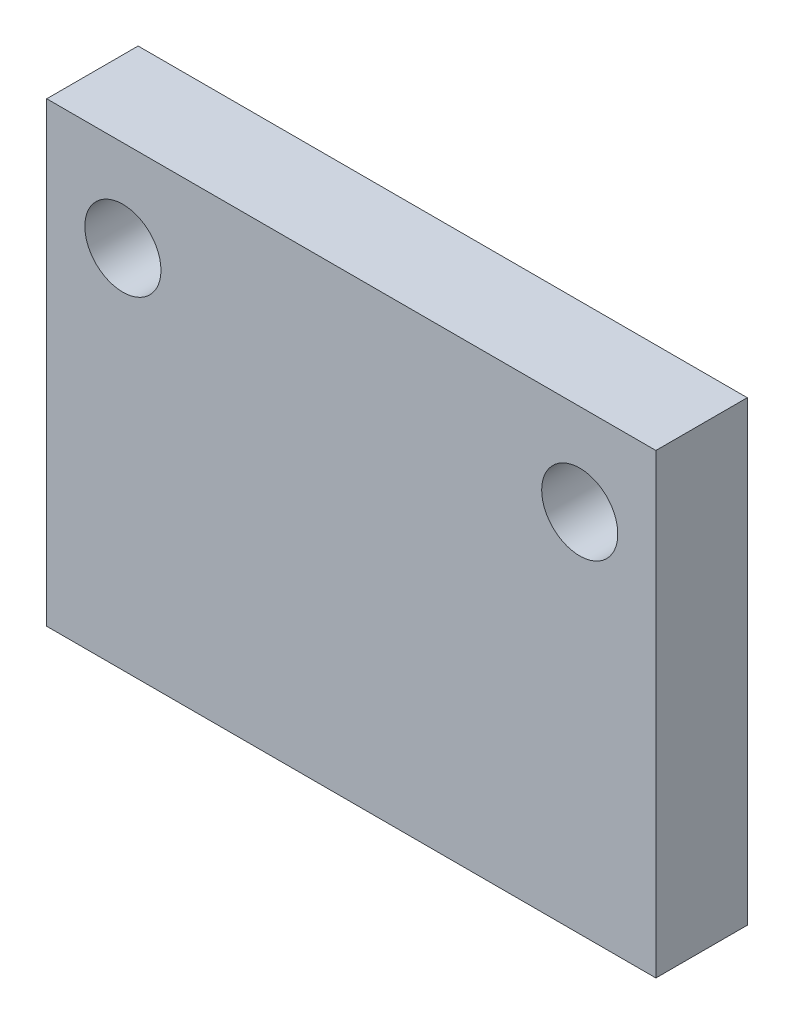
from build123d import *

# Parameters (mm, degrees)
SKETCH_1_W      = 20
SKETCH_1_H      = 15
SKETCH_1_R      = 1.25
EXTRUDE_1_DEPTH = 3


with BuildPart() as part:
    # 草图1 → 凸台-拉伸1 (new body)
    with BuildSketch(Plane.XY):
        Rectangle(SKETCH_1_W, SKETCH_1_H)
        with Locations((-7.5, 4.5)):
            Circle(SKETCH_1_R, mode=Mode.SUBTRACT)
        with Locations((7.5, 4.5)):
            Circle(SKETCH_1_R, mode=Mode.SUBTRACT)
    extrude(amount=EXTRUDE_1_DEPTH)


solid = part.part
